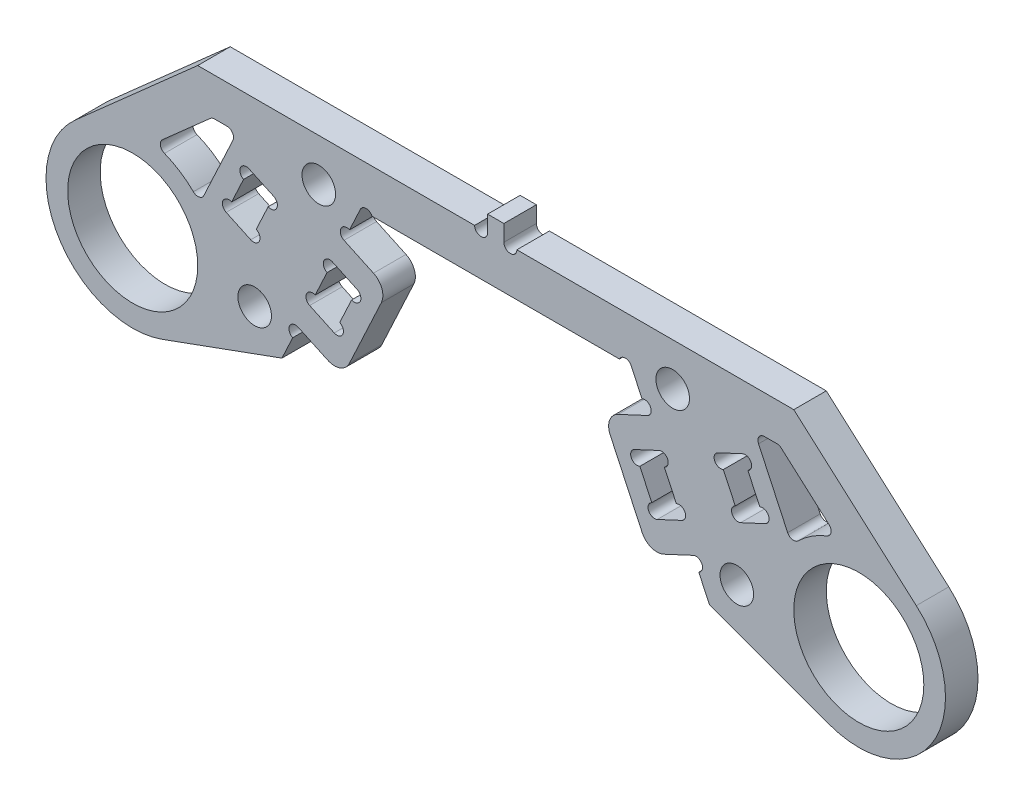
from build123d import *

# Parameters (mm, degrees)
SKETCH_1_R          = 6
EXTRUDE_1_DEPTH     = 1.5
EXTRUDE_2_DEPTH     = 3
SKETCH_6_R          = 0.6
CUT_EXTRUDE_2_DEPTH = 4
FILLET_1_R          = 1.5
SKETCH_7_R          = 1.55
CUT_EXTRUDE_3_DEPTH = 4
CUT_EXTRUDE_4_DEPTH = 4
FILLET_2_R          = 0.6
SKETCH_9_W          = 1.5
SKETCH_9_H          = 1.5
EXTRUDE_3_DEPTH     = 3
SKETCH_10_R         = 0.6
CUT_EXTRUDE_5_DEPTH = 4


with BuildPart() as part:
    # 草图1 → 凸台-拉伸1 (new body, symmetric)
    with BuildSketch(Plane.XY):
        with BuildLine():
            Line((-12.5, 12), (12.5, 12))
            Line((12.5, 12), (19.728184266, -3.500891181))
            Line((19.728184266, -3.500891181), (30.763838853, -7.517540966))
            ThreePointArc((30.763838853, -7.517540966), (40.374225454, -4.092068476), (38.803964436, 5.988986664))
            Line((38.803964436, 5.988986664), (27.5, 16))
            Line((27.5, 16), (-27.5, 16))
            Line((-27.5, 16), (-38.803964436, 5.988986664))
            ThreePointArc((-38.803964436, 5.988986664), (-40.374225454, -4.092068476), (-30.763838853, -7.517540966))
            Line((-30.763838853, -7.517540966), (-19.728184266, -3.500891181))
            Line((-19.728184266, -3.500891181), (-12.5, 12))
        make_face()
        with Locations((-33.5, 0)):
            Circle(SKETCH_1_R, mode=Mode.SUBTRACT)
        with Locations((33.5, 0)):
            Circle(SKETCH_1_R, mode=Mode.SUBTRACT)
    extrude(amount=EXTRUDE_1_DEPTH, both=True)

    # 草图5 → 凸台-拉伸2 (add)
    with BuildSketch(Plane.XY.offset(1.5)):
        Polygon((-14.001000824, 8.781093345), (-9.922615783, 6.879311167), (-14.1487984, -2.183766703), (-18.227183442, -0.281984526), (-17.170637787, 1.983784942), (-14.90486832, 0.927239288), (-12.791777011, 5.458778223), (-15.057546479, 6.515323877), align=None)
        Polygon((14.90486832, 0.927239288), (17.170637787, 1.983784942), (18.227183442, -0.281984526), (14.1487984, -2.183766703), (9.922615783, 6.879311167), (14.001000824, 8.781093345), (15.057546479, 6.515323877), (12.791777011, 5.458778223), align=None)
    extrude(amount=-EXTRUDE_2_DEPTH)

    # 草图6 → 切除-拉伸2 (cut, through all)
    with BuildSketch(Plane.XY.offset(1.5)):
        with Locations((-15.311117436, 5.971539205)):
            Circle(SKETCH_6_R)
        with Locations((-13.045347968, 4.914993551)):
            Circle(SKETCH_6_R)
        with Locations((-16.91706683, 2.527569614)):
            Circle(SKETCH_6_R)
        with Locations((-14.651297363, 1.47102396)):
            Circle(SKETCH_6_R)
        with Locations((-13.747429867, 9.324878017)):
            Circle(SKETCH_6_R)
        with Locations((-18.480754399, -0.825769198)):
            Circle(SKETCH_6_R)
        with Locations((18.480754399, -0.825769198)):
            Circle(SKETCH_6_R)
        with Locations((13.747429867, 9.324878017)):
            Circle(SKETCH_6_R)
        with Locations((14.651297363, 1.47102396)):
            Circle(SKETCH_6_R)
        with Locations((16.91706683, 2.527569614)):
            Circle(SKETCH_6_R)
        with Locations((13.045347968, 4.914993551)):
            Circle(SKETCH_6_R)
        with Locations((15.311117436, 5.971539205)):
            Circle(SKETCH_6_R)
        with Locations((-11.956215328, 11.746429043)):
            Circle(SKETCH_6_R)
        with Locations((11.956215328, 11.746429043)):
            Circle(SKETCH_6_R)
    extrude(amount=-CUT_EXTRUDE_2_DEPTH, mode=Mode.SUBTRACT)

    # 圆角1
    fillet_1_edges = [part.edges().sort_by_distance(p)[0] for p in [
        (-9.922615783, 6.879311167, 0),
        (-14.1487984, -2.183766703, 0),
        (14.1487984, -2.183766703, 0),
        (9.922615783, 6.879311167, 0),
    ]]
    fillet(fillet_1_edges, radius=FILLET_1_R)

    # 草图7 → 切除-拉伸3 (cut, through all)
    with BuildSketch(Plane.XY.offset(1.5)):
        with Locations((-22.24449722, -0.615436184)):
            Circle(SKETCH_7_R)
        with Locations((-16.327841555, 12.072872835)):
            Circle(SKETCH_7_R)
        with Locations((22.24449722, -0.615436184)):
            Circle(SKETCH_7_R)
        with Locations((16.327841555, 12.072872835)):
            Circle(SKETCH_7_R)
    extrude(amount=-CUT_EXTRUDE_3_DEPTH, mode=Mode.SUBTRACT)

    # 草图8 → 切除-拉伸4 (cut, through all)
    with BuildSketch(Plane.XY.offset(1.5)):
        with BuildLine():
            Line((-26.172964956, 12.5), (-31.531802084, 7.754108393))
            ThreePointArc((-31.531802084, 7.754108393), (-29.20884675, 6.751740797), (-27.315064556, 5.074108154))
            Line((-27.315064556, 5.074108154), (-23.85231432, 12.5))
            Line((-23.85231432, 12.5), (-26.172964956, 12.5))
        make_face()
        with BuildLine():
            Line((-22.101342595, 5.607063857), (-21.002535115, 7.963464103))
            ThreePointArc((-21.002535115, 7.963464103), (-20.205179486, 8.253677818), (-20.495393201, 9.051033448))
            Line((-20.495393201, 9.051033448), (-22.761162668, 10.107579102))
            ThreePointArc((-22.761162668, 10.107579102), (-23.558518298, 9.817365387), (-23.268304582, 9.020009758))
            Line((-23.268304582, 9.020009758), (-24.367112063, 6.663609511))
            ThreePointArc((-24.367112063, 6.663609511), (-25.164467692, 6.373395796), (-24.874253977, 5.576040167))
            Line((-24.874253977, 5.576040167), (-22.608484509, 4.519494512))
            ThreePointArc((-22.608484509, 4.519494512), (-21.81112888, 4.809708228), (-22.101342595, 5.607063857))
        make_face()
        with BuildLine():
            Line((24.874253977, 5.576040167), (22.608484509, 4.519494512))
            ThreePointArc((22.608484509, 4.519494512), (21.81112888, 4.809708228), (22.101342595, 5.607063857))
            Line((22.101342595, 5.607063857), (21.002535115, 7.963464103))
            ThreePointArc((21.002535115, 7.963464103), (20.205179486, 8.253677818), (20.495393201, 9.051033448))
            Line((20.495393201, 9.051033448), (22.761162668, 10.107579102))
            ThreePointArc((22.761162668, 10.107579102), (23.558518298, 9.817365387), (23.268304582, 9.020009758))
            Line((23.268304582, 9.020009758), (24.367112063, 6.663609511))
            ThreePointArc((24.367112063, 6.663609511), (25.164467692, 6.373395796), (24.874253977, 5.576040167))
        make_face()
        with BuildLine():
            Line((26.172964956, 12.5), (23.85231432, 12.5))
            Line((23.85231432, 12.5), (27.315064556, 5.074108154))
            ThreePointArc((27.315064556, 5.074108154), (29.20884675, 6.751740797), (31.531802084, 7.754108393))
            Line((31.531802084, 7.754108393), (26.172964956, 12.5))
        make_face()
    extrude(amount=-CUT_EXTRUDE_4_DEPTH, mode=Mode.SUBTRACT)

    # 圆角2
    fillet_2_edges = [part.edges().sort_by_distance(p)[0] for p in [
        (26.172964956, 12.5, 0),
        (31.531802084, 7.754108393, 0),
        (27.315064556, 5.074108154, 0),
        (23.85231432, 12.5, 0),
        (-26.172964956, 12.5, 0),
        (-23.85231432, 12.5, 0),
        (-27.315064556, 5.074108154, 0),
        (-31.531802084, 7.754108393, 0),
    ]]
    fillet(fillet_2_edges, radius=FILLET_2_R)

    # 草图9 → 凸台-拉伸3 (add)
    with BuildSketch(Plane.XY.offset(1.5)):
        with Locations((0, 16.75)):
            Rectangle(SKETCH_9_W, SKETCH_9_H)
    extrude(amount=-EXTRUDE_3_DEPTH)

    # 草图10 → 切除-拉伸5 (cut, through all)
    with BuildSketch(Plane.XY.offset(1.5)):
        with Locations((1.35, 16)):
            Circle(SKETCH_10_R)
        with Locations((-1.35, 16)):
            Circle(SKETCH_10_R)
    extrude(amount=-CUT_EXTRUDE_5_DEPTH, mode=Mode.SUBTRACT)


solid = part.part
